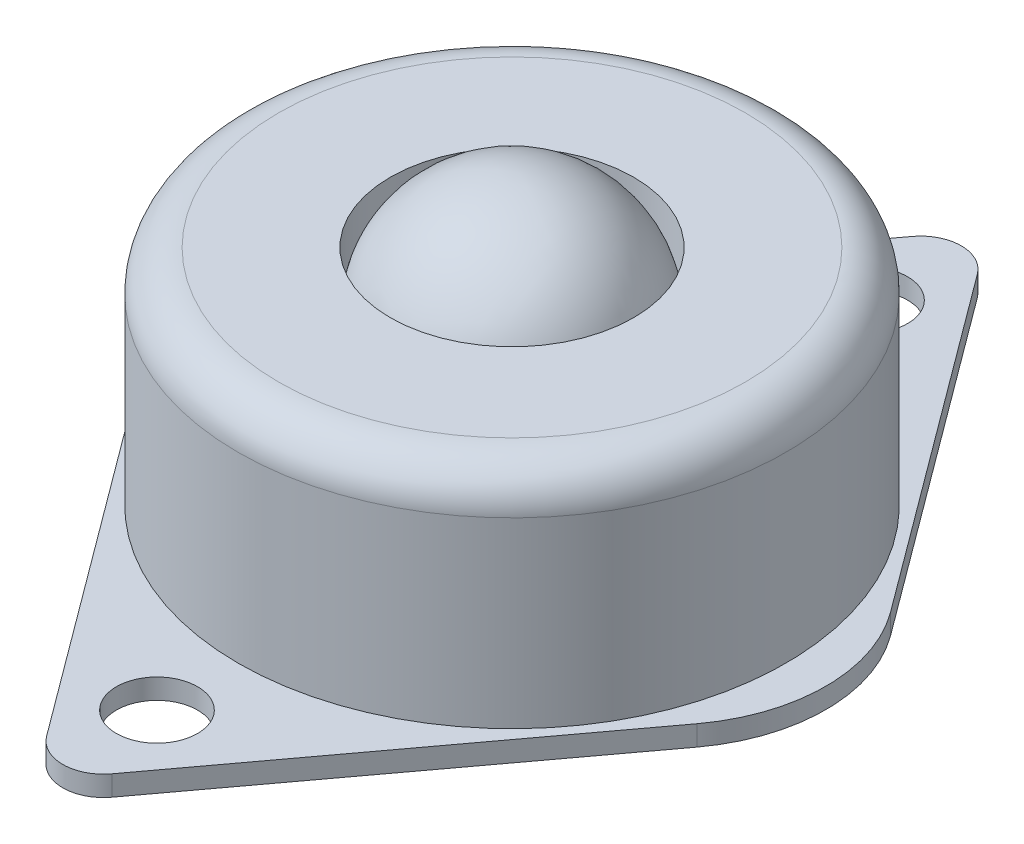
from build123d import *

# Parameters (mm, degrees)
SKETCH_1_R      = 2
SKETCH_1_R_2    = 14
EXTRUDE_1_DEPTH = 1
SKETCH_2_R      = 13.5
SKETCH_2_R_2    = 6
EXTRUDE_2_DEPTH = 11
FILLET_1_R      = 2


with BuildPart() as part:
    # 草图1 → 凸台-拉伸1 (new body)
    with BuildSketch(Plane(origin=(0, 0, 0), x_dir=(1, 0, 0), z_dir=(0, 1, 0))):
        with BuildLine():
            ThreePointArc((1.606347752, 21.334346505), (0, 22.142857143), (-1.606347752, 21.334346505))
            Line((-1.606347752, 21.334346505), (-11.244434288, 8.340425501))
            ThreePointArc((-11.244434288, 8.340425501), (5.1e-08, 14), (11.244434349, 8.340425419))
            Line((11.244434349, 8.340425419), (1.606347752, 21.334346505))
        make_face()
        with Locations((0, 17.5)):
            Circle(SKETCH_1_R, mode=Mode.SUBTRACT)
        Circle(SKETCH_1_R_2)
        with BuildLine():
            Line((13.895753503, 4.765957447), (11.244434349, 8.340425419))
            ThreePointArc((11.244434349, 8.340425419), (13.293270495, 4.391919803), (14, 0))
            ThreePointArc((14, 0), (13.293270397, -4.3919201), (11.244433977, -8.340425921))
            Line((11.244433977, -8.340425921), (13.895753503, -4.765957447))
            ThreePointArc((13.895753503, -4.765957447), (15.470362494, 0), (13.895753503, 4.765957447))
        make_face()
        with BuildLine():
            ThreePointArc((11.244433977, -8.340425921), (-1.78e-07, -14), (-11.244434189, -8.340425635))
            Line((-11.244434189, -8.340425635), (-1.606347752, -21.334346505))
            ThreePointArc((-1.606347752, -21.334346505), (0, -22.142857143), (1.606347752, -21.334346505))
            Line((1.606347752, -21.334346505), (11.244433977, -8.340425921))
        make_face()
        with Locations((0, -17.5)):
            Circle(SKETCH_1_R, mode=Mode.SUBTRACT)
        with BuildLine():
            ThreePointArc((-11.244434189, -8.340425635), (-14, -8.3e-08), (-11.244434288, 8.340425501))
            Line((-11.244434288, 8.340425501), (-13.895753503, 4.765957447))
            ThreePointArc((-13.895753503, 4.765957447), (-15.470362494, 0), (-13.895753503, -4.765957447))
            Line((-13.895753503, -4.765957447), (-11.244434189, -8.340425635))
        make_face()
    extrude(amount=EXTRUDE_1_DEPTH)

    # 草图2 → 凸台-拉伸2 (add)
    with BuildSketch(Plane(origin=(0, 1, 0), x_dir=(1, 0, 0), z_dir=(0, 1, 0))):
        Circle(SKETCH_2_R)
        Circle(SKETCH_2_R_2, mode=Mode.SUBTRACT)
    extrude(amount=EXTRUDE_2_DEPTH)

    # 圆角1
    fillet_1_edges = [part.edges().sort_by_distance(p)[0] for p in [
        (-13.5, 12, 0),
    ]]
    fillet(fillet_1_edges, radius=FILLET_1_R)


with BuildPart() as body_2:
    # 草图5 one side → 旋转3 (revolve)
    with BuildSketch(Plane(origin=(0, 9, 0), x_dir=(1, 0, 0), z_dir=(0, 1, 0))):
        with BuildLine():
            Line((6, 0), (-6, 0))
            ThreePointArc((-6, 0), (0, -6), (6, 0))
        make_face()
    revolve(axis=Axis((6, 9, 0), (-1, 0, 0)))


solid = Compound([part.part, body_2.part])
